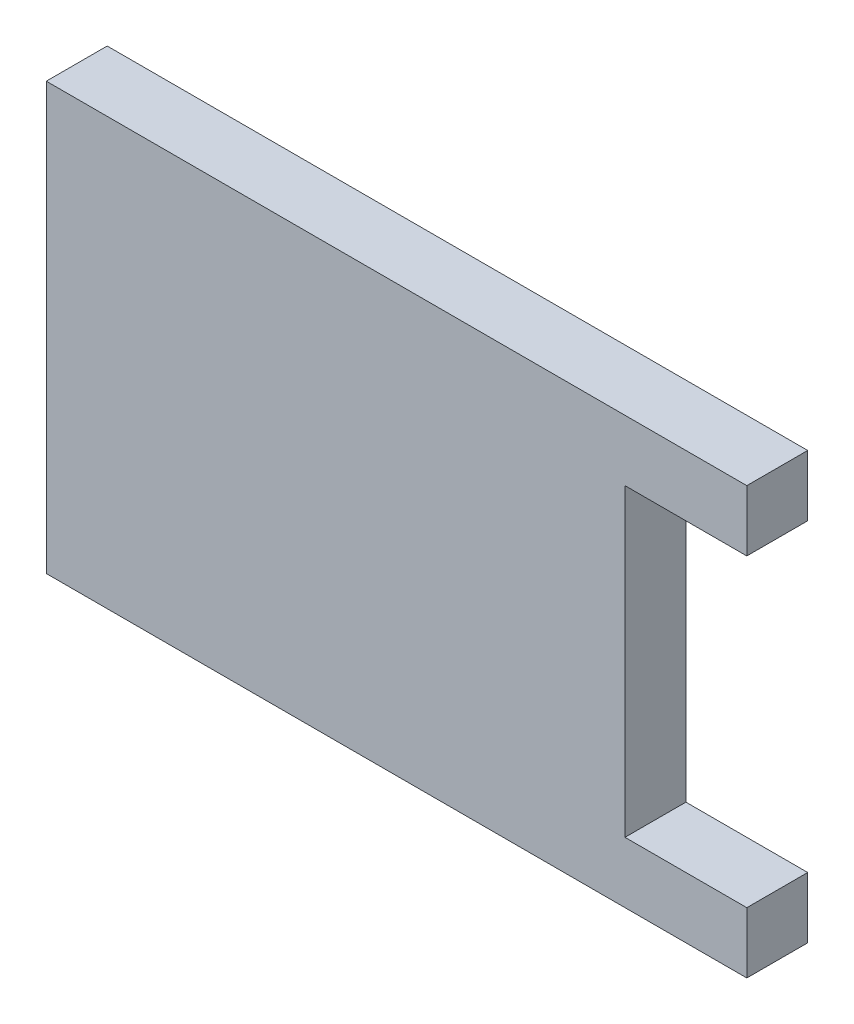
from build123d import *

# Parameters (mm, degrees)
SKETCH1_W      = 23
SKETCH1_H      = 14
EXTRUDE1_DEPTH = 2
SKETCH3_W      = 4
SKETCH3_H      = 10
EXTRUDE3_DEPTH = 2


with BuildPart() as part:
    # Sketch1 → Extrude1 (new body)
    with BuildSketch(Plane.XY):
        Rectangle(SKETCH1_W, SKETCH1_H)
    extrude(amount=EXTRUDE1_DEPTH)

    # Sketch3 → Extrude3 (cut)
    with BuildSketch(Plane.XY.offset(2)):
        with Locations((9.5, 0)):
            Rectangle(SKETCH3_W, SKETCH3_H)
    extrude(amount=-EXTRUDE3_DEPTH, mode=Mode.SUBTRACT)


solid = part.part
